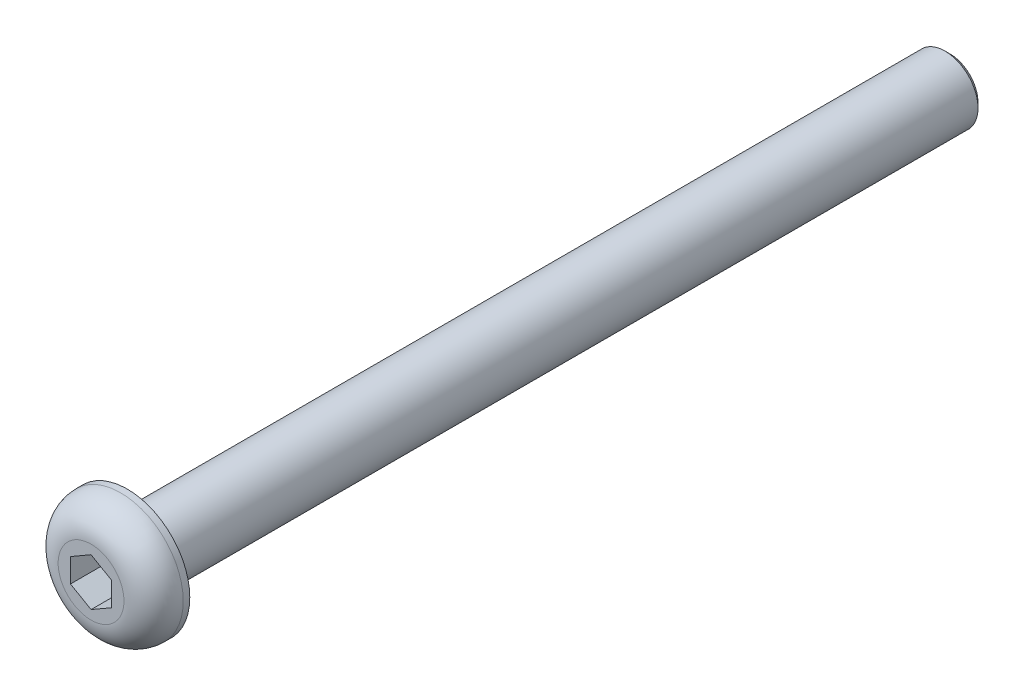
from build123d import *

# Parameters (mm, degrees)
SKETCH1_R           = 3.8
BOSS_EXTRUDE1_DEPTH = 2.2
SKETCH2_R           = 2
BOSS_EXTRUDE2_DEPTH = 50
CHAMFER1_SIZE       = 0.3
CUT_EXTRUDE1_DEPTH  = 2
FILLET1_R           = 1.8


with BuildPart() as part:
    # Sketch1 → Boss-Extrude1 (new body)
    with BuildSketch(Plane.XY):
        Circle(SKETCH1_R)
    extrude(amount=BOSS_EXTRUDE1_DEPTH)

    # Sketch2 → Boss-Extrude2 (add)
    with BuildSketch(Plane(origin=(0, 0, 0), x_dir=(-1, 0, 0), z_dir=(0, 0, -1))):
        Circle(SKETCH2_R)
    extrude(amount=BOSS_EXTRUDE2_DEPTH)

    # Chamfer1
    chamfer1_edges = [part.edges().sort_by_distance(p)[0] for p in [
        (2, 0, -50),
    ]]
    chamfer(chamfer1_edges, length=CHAMFER1_SIZE)

    # Sketch3 → Cut-Extrude1 (cut)
    with BuildSketch(Plane.XY.offset(2.2)):
        Polygon((0, 1.443375673), (-1.25, 0.721687836), (-1.25, -0.721687836), (0, -1.443375673), (1.25, -0.721687836), (1.25, 0.721687836), align=None)
    extrude(amount=-CUT_EXTRUDE1_DEPTH, mode=Mode.SUBTRACT)

    # Fillet1
    fillet1_edges = [part.edges().sort_by_distance(p)[0] for p in [
        (-3.8, 0, 2.2),
    ]]
    fillet(fillet1_edges, radius=FILLET1_R)


solid = part.part
